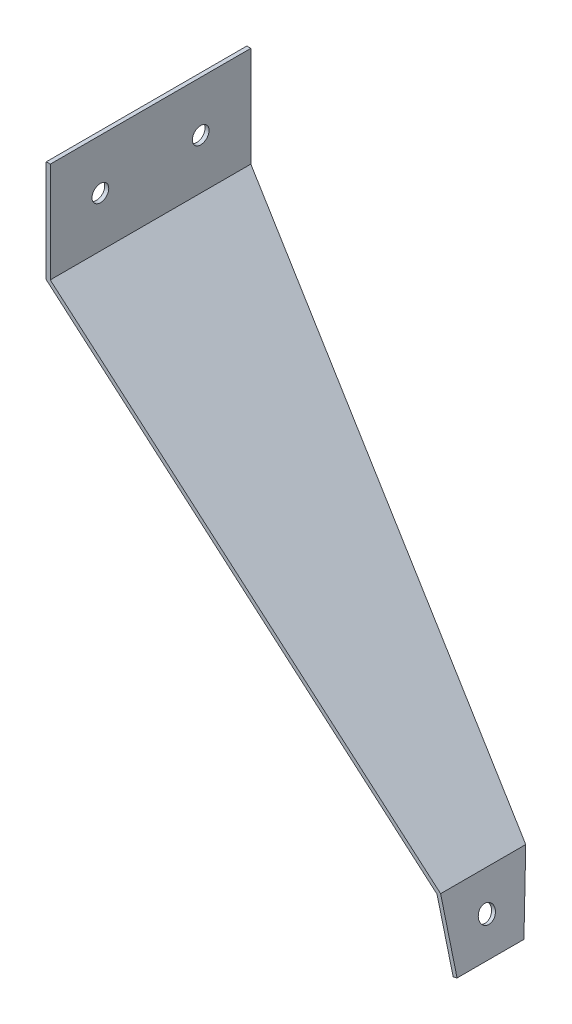
from build123d import *

# Parameters (mm, degrees)
BOSS_EXTRUDE1_DEPTH = 76.2
CUT_EXTRUDE1_DEPTH  = 152.364149309
SKETCH3_R           = 3.175
CUT_EXTRUDE2_DEPTH  = 152.364149309
SKETCH4_R           = 3.175
CUT_EXTRUDE3_DEPTH  = 2.524


with BuildPart() as part:
    # Sketch1 → Boss-Extrude1 (new body)
    with BuildSketch(Plane.XY):
        Polygon((0, 0), (0, 38.1), (-1.524, 38.1), (-1.524, -0.698546195), (146.938943833, -128.622402846), (153.072957039, -152.775137619), (154.550064945, -152.4), (148.297771302, -127.781534893), align=None)
    extrude(amount=-BOSS_EXTRUDE1_DEPTH)

    # Sketch2 → Cut-Extrude1 (cut, through all)
    with BuildSketch(Plane(origin=(108.826155859, 27.638322679, 0), x_dir=(0, 0, -1), z_dir=(0.96923091, 0.246153293, 0))):
        Polygon((25.4, -185.753798063), (76.2, 0), (76.2, -185.753798063), align=None)
    extrude(amount=-CUT_EXTRUDE1_DEPTH, mode=Mode.SUBTRACT)

    # Sketch3 → Cut-Extrude2 (cut, through all)
    with BuildSketch(Plane(origin=(108.826155859, 27.638322679, 0), x_dir=(0, 0, -1), z_dir=(0.96923091, 0.246153293, 0))):
        with Locations((14.436599754, -173.053798063)):
            Circle(SKETCH3_R)
    extrude(amount=-CUT_EXTRUDE2_DEPTH, mode=Mode.SUBTRACT)

    # Sketch4 → Cut-Extrude3 (cut, through all)
    with BuildSketch(Plane(origin=(0, 0, 0), x_dir=(0, 0, -1), z_dir=(1, 0, 0))):
        with Locations((19.05, 19.05)):
            Circle(SKETCH4_R)
        with Locations((57.15, 19.05)):
            Circle(SKETCH4_R)
    extrude(amount=-CUT_EXTRUDE3_DEPTH, mode=Mode.SUBTRACT)


solid = part.part
